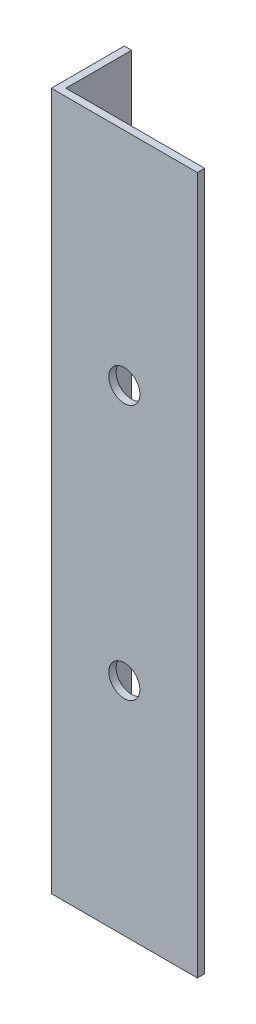
from build123d import *

# Parameters (mm, degrees)
EXTRUDE_1_DEPTH     = 191
SKETCH_2_R          = 4.25
CUT_EXTRUDE_1_DEPTH = 21
SKETCH_3_R          = 2.25
CUT_EXTRUDE_2_DEPTH = 3


with BuildPart() as part:
    # Эскиз1 → Бобышка-Вытянуть1 (new body)
    with BuildSketch(Plane(origin=(0, 0, 0), x_dir=(1, 0, 0), z_dir=(0, 1, 0))):
        Polygon((0, 0), (0, 20), (2, 20), (2, 2), (40, 2), (40, 0), align=None)
    extrude(amount=EXTRUDE_1_DEPTH)

    # Эскиз2 → Вырез-Вытянуть1 (cut, through all)
    with BuildSketch(Plane.XY):
        with Locations((20, 130.5)):
            Circle(SKETCH_2_R)
        with Locations((20, 60.5)):
            Circle(SKETCH_2_R)
    extrude(amount=-CUT_EXTRUDE_1_DEPTH, mode=Mode.SUBTRACT)

    # Эскиз3 → Вырез-Вытянуть2 (cut, through all)
    with BuildSketch(Plane(origin=(2, 0, 0), x_dir=(0, 0, -1), z_dir=(1, 0, 0))):
        with Locations((10, 12)):
            Circle(SKETCH_3_R)
        with Locations((10, 179)):
            Circle(SKETCH_3_R)
    extrude(amount=-CUT_EXTRUDE_2_DEPTH, mode=Mode.SUBTRACT)


solid = part.part
